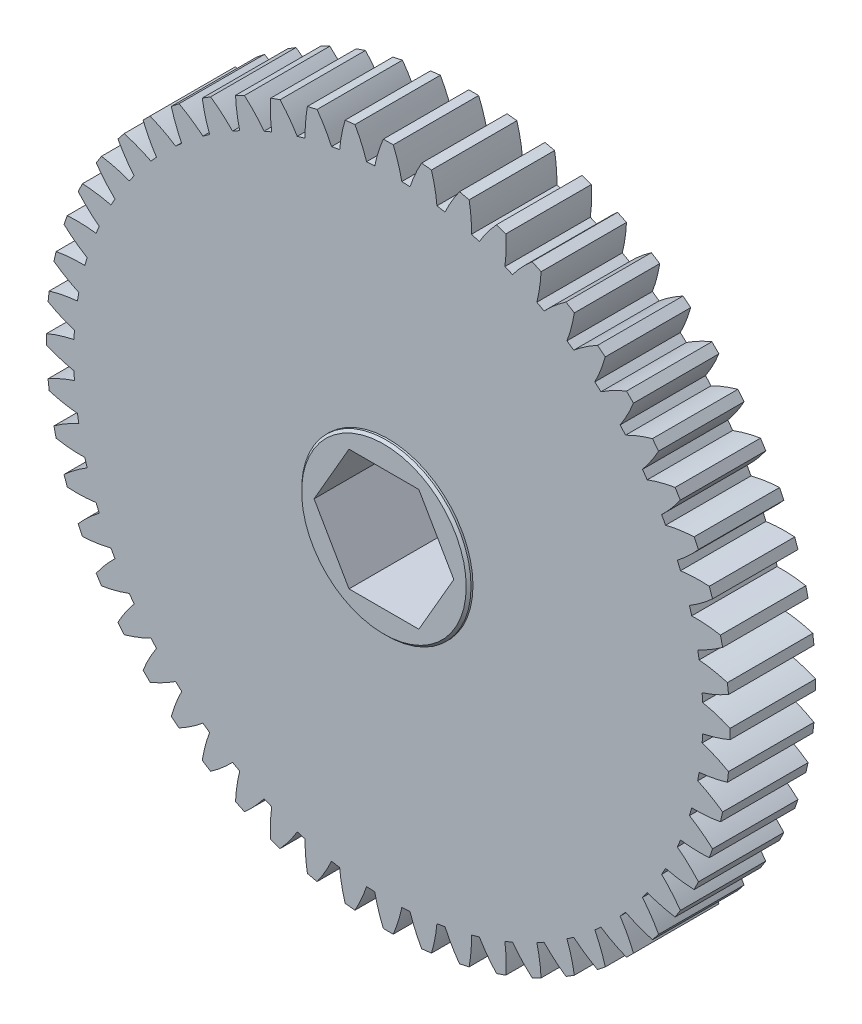
from build123d import *

# Parameters (mm, degrees)
SKETCH1_R           = 33.02
EXTRUDE1_DEPTH      = 4.4831
EXTRUDE2_DEPTH      = 8.9662
CIRPATTERN1_COUNT   = 56
SKETCH6_R           = 8.89
EXTRUDE4_DEPTH      = 4.9403
EXTRUDE4_DEPTH_BACK = 4.9403
CHAMFER1_SIZE       = 0.254
EXTRUDE3_DEPTH      = 5.9403
EXTRUDE3_DEPTH_BACK = 5.9403


with BuildPart() as part:
    # Sketch1 → Extrude1 (new body, symmetric)
    with BuildSketch(Plane.XY):
        Circle(SKETCH1_R)
    extrude(amount=EXTRUDE1_DEPTH, both=True)

    # Sketch2 → Extrude2 (add)
    with BuildSketch(Plane(origin=(0, 0, -4.4831), x_dir=(-1, 0, 0), z_dir=(0, 0, -1))):
        with BuildLine():
            Line((35.8775, 0.51867689), (35.8775, -0.51867689))
            ThreePointArc((35.8775, -0.51867689), (34.455917653, -1.041662337), (32.989416236, -1.4208506))
            ThreePointArc((32.989416236, -1.4208506), (33.02, 0), (32.989416236, 1.4208506))
            ThreePointArc((32.989416236, 1.4208506), (34.455917653, 1.041662337), (35.8775, 0.51867689))
        make_face()
    extrude2 = extrude(amount=-EXTRUDE2_DEPTH)

    # CirPattern1: Extrude2 ×56 about axis
    cirpattern1_axis = Axis((0, 0, 0), (0, 0, 1))
    for i in range(1, CIRPATTERN1_COUNT):
        add(extrude2.rotate(cirpattern1_axis, i * 360 / CIRPATTERN1_COUNT))

    # Sketch6 → Extrude4 (add, two sides)
    with BuildSketch(Plane.XY) as extrude4_sk:
        Circle(SKETCH6_R)
    extrude(amount=EXTRUDE4_DEPTH)
    extrude(extrude4_sk.sketch, amount=-EXTRUDE4_DEPTH_BACK)

    # Chamfer1
    chamfer1_edges = [part.edges().sort_by_distance(p)[0] for p in [
        (-8.89, 0, 4.9403),
        (-8.89, 0, -4.9403),
    ]]
    chamfer(chamfer1_edges, length=CHAMFER1_SIZE)

    # Sketch4 → Extrude3 (cut, two sides)
    with BuildSketch(Plane.XY) as extrude3_sk:
        Polygon((-3.666174209, -6.35), (3.666174209, -6.35), (7.332348419, 0), (3.666174209, 6.35), (-3.666174209, 6.35), (-7.332348419, 0), align=None)
    extrude(amount=EXTRUDE3_DEPTH, mode=Mode.SUBTRACT)
    extrude(extrude3_sk.sketch, amount=-EXTRUDE3_DEPTH_BACK, mode=Mode.SUBTRACT)


solid = part.part
